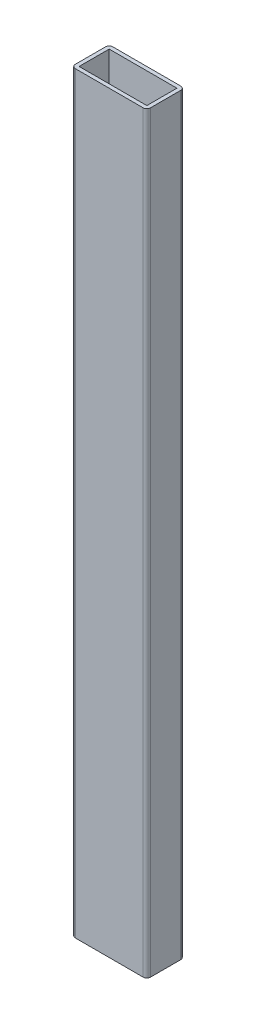
from build123d import *

# Parameters (mm, degrees)
SKETCH_1_W      = 36
SKETCH_1_H      = 16
EXTRUDE_1_DEPTH = 400


with BuildPart() as part:
    # Эскиз1 → Вытянуть-Тонкостенный1 (new body)
    with BuildSketch(Plane(origin=(0, 0, 0), x_dir=(1, 0, 0), z_dir=(0, 1, 0))):
        with BuildLine():
            Line((-18, 10), (18, 10))
            ThreePointArc((18, 10), (19.414213562, 9.414213562), (20, 8))
            Line((20, 8), (20, -8))
            ThreePointArc((20, -8), (19.414213562, -9.414213562), (18, -10))
            Line((18, -10), (-18, -10))
            ThreePointArc((-18, -10), (-19.414213562, -9.414213562), (-20, -8))
            Line((-20, -8), (-20, 8))
            ThreePointArc((-20, 8), (-19.414213562, 9.414213562), (-18, 10))
        make_face()
        Rectangle(SKETCH_1_W, SKETCH_1_H, mode=Mode.SUBTRACT)
    extrude(amount=EXTRUDE_1_DEPTH)


solid = part.part
